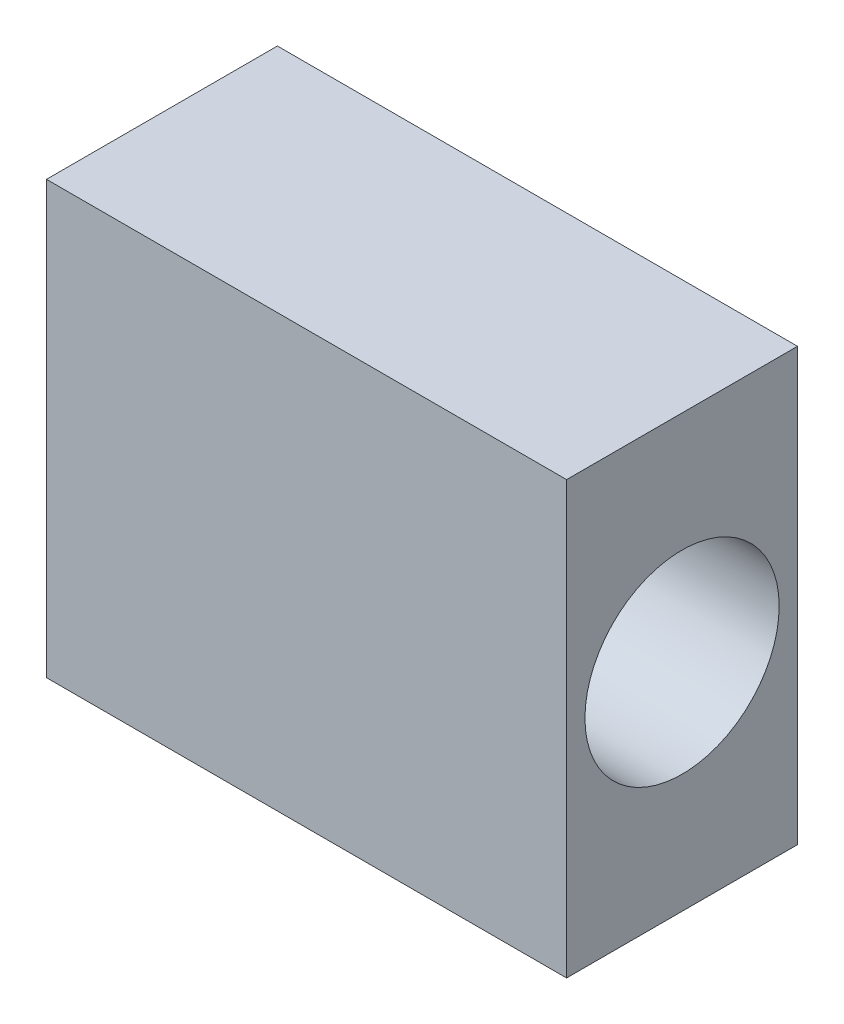
from build123d import *

# Parameters (mm, degrees)
SKETCH1_W           = 12.05
SKETCH1_H           = 5.35
BOSS_EXTRUDE1_DEPTH = 10
SKETCH3_R           = 2.25
CUT_EXTRUDE2_DEPTH  = 12.05


with BuildPart() as part:
    # Sketch1 → Boss-Extrude1 (new body)
    with BuildSketch(Plane(origin=(0, 0, 0), x_dir=(1, 0, 0), z_dir=(0, 1, 0))):
        with Locations((6.025, 2.675)):
            Rectangle(SKETCH1_W, SKETCH1_H)
    extrude(amount=BOSS_EXTRUDE1_DEPTH)

    # Sketch3 → Cut-Extrude2 (cut)
    with BuildSketch(Plane.ZY):
        with Locations((-2.675, 5)):
            Circle(SKETCH3_R)
    extrude(amount=-CUT_EXTRUDE2_DEPTH, mode=Mode.SUBTRACT)


solid = part.part
